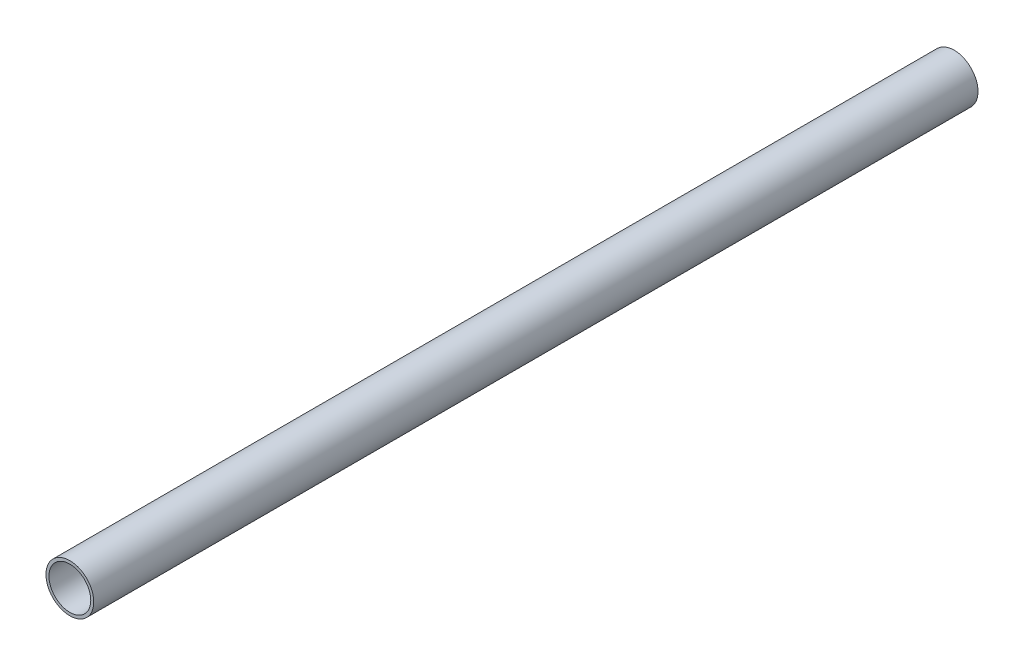
from build123d import *

# Parameters (mm, degrees)
SKETCH1_R           = 12.7
SKETCH1_R_2         = 11.1125
BOSS_EXTRUDE1_DEPTH = 469.9


with BuildPart() as part:
    # Sketch1 → Boss-Extrude1 (new body)
    with BuildSketch(Plane.XY):
        Circle(SKETCH1_R)
        Circle(SKETCH1_R_2, mode=Mode.SUBTRACT)
    extrude(amount=BOSS_EXTRUDE1_DEPTH)


solid = part.part
